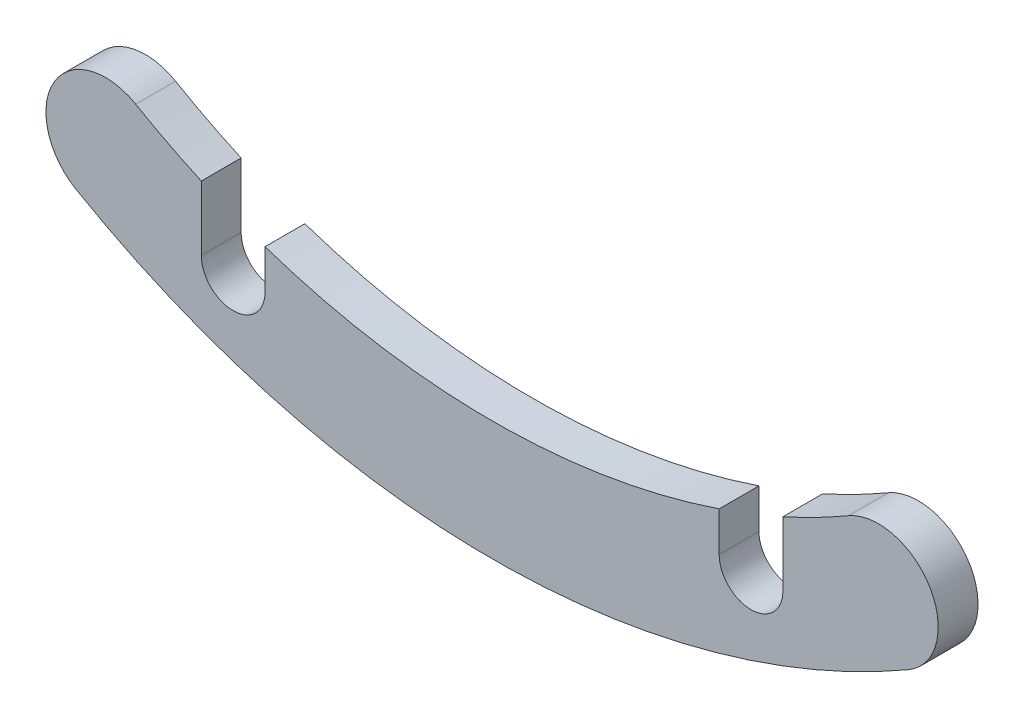
from build123d import *

# Parameters (mm, degrees)
BOSS_EXTRUDE1_DEPTH = 1
CUT_EXTRUDE1_DEPTH  = 2


with BuildPart() as part:
    # Sketch1 → Boss-Extrude1 (new body)
    with BuildSketch(Plane.XY):
        with BuildLine():
            ThreePointArc((-10.45388601, -17.982109645), (0, -20.8), (10.45388601, -17.982109645))
            ThreePointArc((10.45388601, -17.982109645), (10.996786753, -15.931436881), (8.94611399, -15.388536138))
            ThreePointArc((8.94611399, -15.388536138), (0, -17.8), (-8.94611399, -15.388536138))
            ThreePointArc((-8.94611399, -15.388536138), (-10.996786753, -15.931436881), (-10.45388601, -17.982109645))
        make_face()
    extrude(amount=-BOSS_EXTRUDE1_DEPTH)

    # Sketch2 → Cut-Extrude1 (cut, through all)
    with BuildSketch(Plane.XY):
        with BuildLine():
            Line((-7.3, -17.853571071), (-7.3, -16.23422311))
            ThreePointArc((-7.3, -16.23422311), (-6.507590932, -16.567777771), (-5.7, -16.862680688))
            Line((-5.7, -16.862680688), (-5.7, -17.853571071))
            ThreePointArc((-5.7, -17.853571071), (-6.5, -18.653571071), (-7.3, -17.853571071))
        make_face()
        with BuildLine():
            Line((5.7, -17.853571071), (5.7, -16.862680688))
            ThreePointArc((5.7, -16.862680688), (6.507590932, -16.567777771), (7.3, -16.23422311))
            Line((7.3, -16.23422311), (7.3, -17.853571071))
            ThreePointArc((7.3, -17.853571071), (6.5, -18.653571071), (5.7, -17.853571071))
        make_face()
    extrude(amount=-CUT_EXTRUDE1_DEPTH, mode=Mode.SUBTRACT)


solid = part.part
